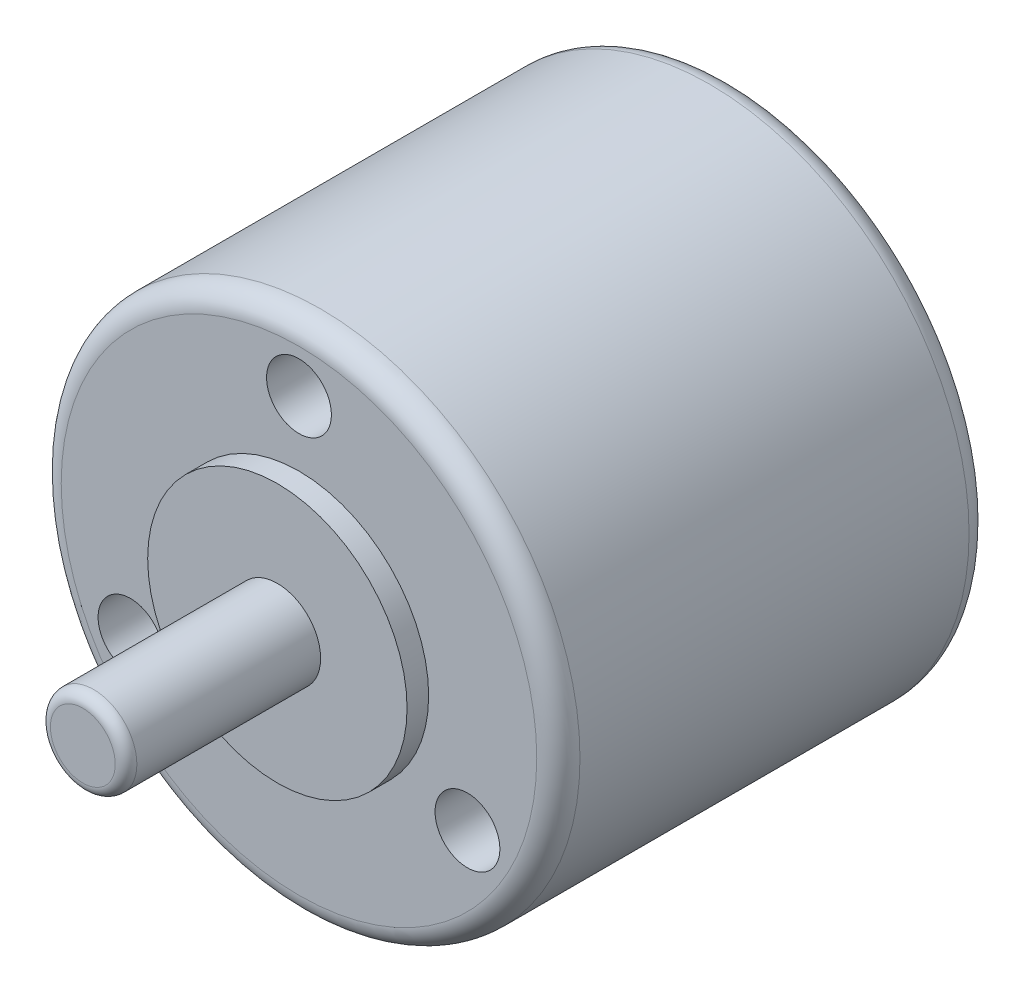
from build123d import *

# Parameters (mm, degrees)
ESQUISSE1_R             = 12
EXTRUSION1_DEPTH        = 20
ESQUISSE2_R             = 2
EXTRUSION2_DEPTH        = 10
CONG_1_R                = 1
CONG_2_R                = 1
CONG_3_R                = 0.5
ESQUISSE4_R             = 6
EXTRUSION3_DEPTH        = 1
ESQUISSE5_R             = 1.5
ENL_V_MAT_EXTRU_1_DEPTH = 5


with BuildPart() as part:
    # Esquisse1 → Extrusion1 (new body)
    with BuildSketch(Plane.XY):
        Circle(ESQUISSE1_R)
    extrude(amount=-EXTRUSION1_DEPTH)

    # Esquisse2 → Extrusion2 (add)
    with BuildSketch(Plane.XY):
        Circle(ESQUISSE2_R)
    extrude(amount=EXTRUSION2_DEPTH)

    # Congé1
    cong_1_edges = [part.edges().sort_by_distance(p)[0] for p in [
        (-12, 0, 0),
    ]]
    fillet(cong_1_edges, radius=CONG_1_R)

    # Congé2
    cong_2_edges = [part.edges().sort_by_distance(p)[0] for p in [
        (-12, 0, -20),
    ]]
    fillet(cong_2_edges, radius=CONG_2_R)

    # Congé3
    cong_3_edges = [part.edges().sort_by_distance(p)[0] for p in [
        (-2, 0, 10),
    ]]
    fillet(cong_3_edges, radius=CONG_3_R)

    # Esquisse4 → Extrusion3 (add)
    with BuildSketch(Plane.XY):
        Circle(ESQUISSE4_R)
    extrude(amount=EXTRUSION3_DEPTH)

    # Esquisse5 → Enlèv. mat.-Extru.1 (cut)
    with BuildSketch(Plane.XY):
        with Locations((0, 9)):
            Circle(ESQUISSE5_R)
        with Locations((-7.794228634, -4.5)):
            Circle(ESQUISSE5_R)
        with Locations((7.794228634, -4.5)):
            Circle(ESQUISSE5_R)
    extrude(amount=-ENL_V_MAT_EXTRU_1_DEPTH, mode=Mode.SUBTRACT)


solid = part.part
